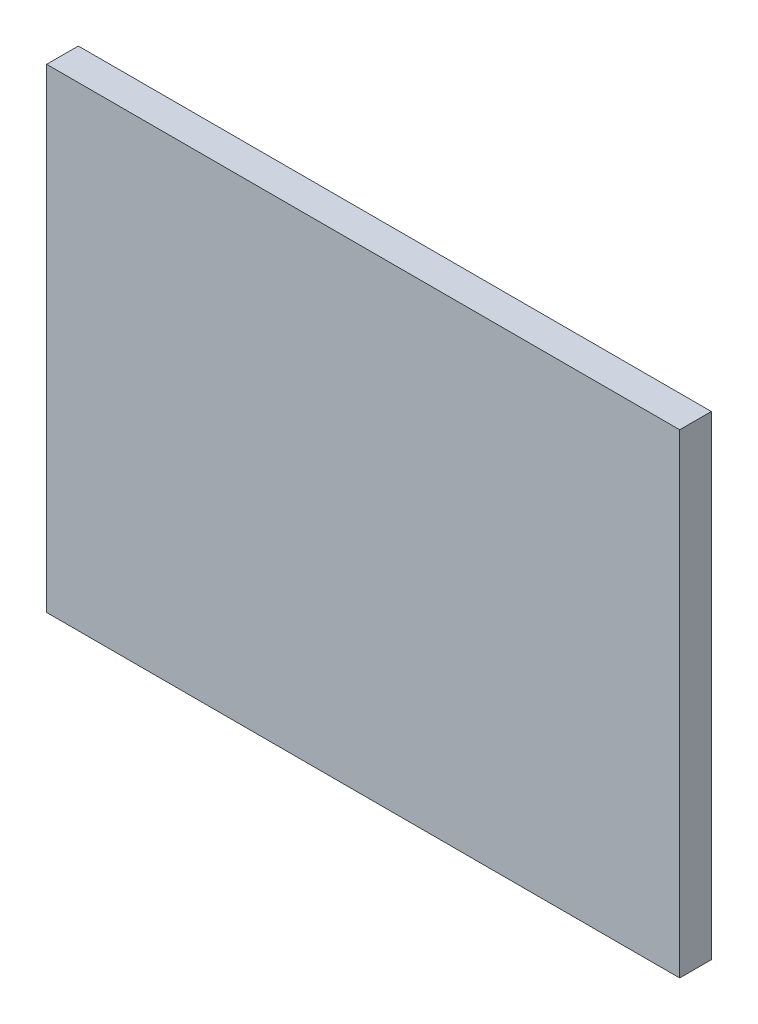
from build123d import *

# Parameters (mm, degrees)
SKETCH1_W           = 20
SKETCH1_H           = 15
BOSS_EXTRUDE1_DEPTH = 1


with BuildPart() as part:
    # Sketch1 → Boss-Extrude1 (new body)
    with BuildSketch(Plane.XY):
        Rectangle(SKETCH1_W, SKETCH1_H)
    extrude(amount=BOSS_EXTRUDE1_DEPTH)


solid = part.part
